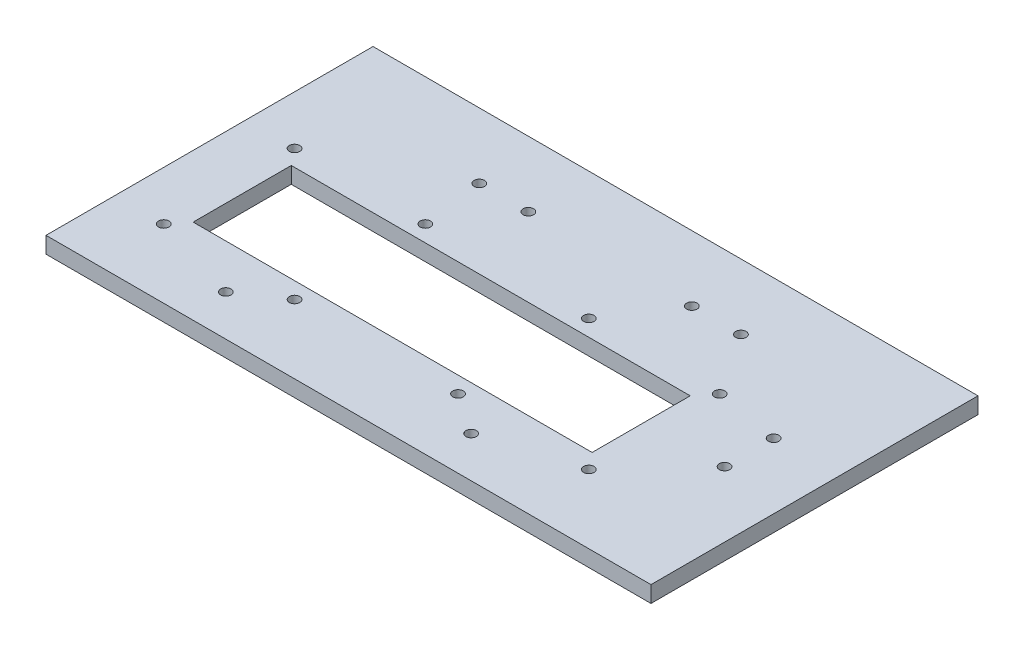
from build123d import *

# Parameters (mm, degrees)
SKETCH1_W           = 185
SKETCH1_H           = 100
SKETCH1_W_2         = 122
SKETCH1_H_2         = 30
BOSS_EXTRUDE1_DEPTH = 5
CUT_EXTRUDE2_REACH  = 7
SKETCH2_R           = 1.6
CUT_EXTRUDE3_REACH  = 7
SKETCH3_R           = 1.6
CUT_EXTRUDE4_REACH  = 7
SKETCH4_R           = 1.6
CUT_EXTRUDE5_REACH  = 7
SKETCH5_R           = 1.6


with BuildPart() as part:
    # Sketch1 → Boss-Extrude1 (new body)
    with BuildSketch(Plane(origin=(0, 0, 0), x_dir=(1, 0, 0), z_dir=(0, 1, 0))):
        with Locations((12.5, 9)):
            Rectangle(SKETCH1_W, SKETCH1_H)
        Rectangle(SKETCH1_W_2, SKETCH1_H_2, mode=Mode.SUBTRACT)
    extrude(amount=BOSS_EXTRUDE1_DEPTH)

    # Sketch2 → Cut-Extrude2 (cut, up to next)
    with BuildSketch(Plane(origin=(0, 0, 0), x_dir=(1, 0, 0), z_dir=(0, 1, 0)), mode=Mode.PRIVATE) as cut_extrude2_sk1:
        with Locations((-25, 20)):
            Circle(SKETCH2_R)
    cut_extrude2_tool1 = extrude(cut_extrude2_sk1.sketch, amount=CUT_EXTRUDE2_REACH, mode=Mode.PRIVATE) & part.part
    add(cut_extrude2_tool1.solids().sort_by_distance((-25, 0, -20))[0], mode=Mode.SUBTRACT)
    # Sketch2 → Cut-Extrude2 (cut, up to next)
    with BuildSketch(Plane(origin=(0, 0, 0), x_dir=(1, 0, 0), z_dir=(0, 1, 0)), mode=Mode.PRIVATE) as cut_extrude2_sk2:
        with Locations((25, 20)):
            Circle(SKETCH2_R)
    cut_extrude2_tool2 = extrude(cut_extrude2_sk2.sketch, amount=CUT_EXTRUDE2_REACH, mode=Mode.PRIVATE) & part.part
    add(cut_extrude2_tool2.solids().sort_by_distance((25, 0, -20))[0], mode=Mode.SUBTRACT)
    # Sketch2 → Cut-Extrude2 (cut, up to next)
    with BuildSketch(Plane(origin=(0, 0, 0), x_dir=(1, 0, 0), z_dir=(0, 1, 0)), mode=Mode.PRIVATE) as cut_extrude2_sk3:
        with Locations((25, -20)):
            Circle(SKETCH2_R)
    cut_extrude2_tool3 = extrude(cut_extrude2_sk3.sketch, amount=CUT_EXTRUDE2_REACH, mode=Mode.PRIVATE) & part.part
    add(cut_extrude2_tool3.solids().sort_by_distance((25, 0, 20))[0], mode=Mode.SUBTRACT)
    # Sketch2 → Cut-Extrude2 (cut, up to next)
    with BuildSketch(Plane(origin=(0, 0, 0), x_dir=(1, 0, 0), z_dir=(0, 1, 0)), mode=Mode.PRIVATE) as cut_extrude2_sk4:
        with Locations((-25, -20)):
            Circle(SKETCH2_R)
    cut_extrude2_tool4 = extrude(cut_extrude2_sk4.sketch, amount=CUT_EXTRUDE2_REACH, mode=Mode.PRIVATE) & part.part
    add(cut_extrude2_tool4.solids().sort_by_distance((-25, 0, 20))[0], mode=Mode.SUBTRACT)
    # Sketch2 → Cut-Extrude2 (cut, up to next)
    with BuildSketch(Plane(origin=(0, 0, 0), x_dir=(1, 0, 0), z_dir=(0, 1, 0)), mode=Mode.PRIVATE) as cut_extrude2_sk5:
        with Locations((-65, 20)):
            Circle(SKETCH2_R)
    cut_extrude2_tool5 = extrude(cut_extrude2_sk5.sketch, amount=CUT_EXTRUDE2_REACH, mode=Mode.PRIVATE) & part.part
    add(cut_extrude2_tool5.solids().sort_by_distance((-65, 0, -20))[0], mode=Mode.SUBTRACT)
    # Sketch2 → Cut-Extrude2 (cut, up to next)
    with BuildSketch(Plane(origin=(0, 0, 0), x_dir=(1, 0, 0), z_dir=(0, 1, 0)), mode=Mode.PRIVATE) as cut_extrude2_sk6:
        with Locations((65, 20)):
            Circle(SKETCH2_R)
    cut_extrude2_tool6 = extrude(cut_extrude2_sk6.sketch, amount=CUT_EXTRUDE2_REACH, mode=Mode.PRIVATE) & part.part
    add(cut_extrude2_tool6.solids().sort_by_distance((65, 0, -20))[0], mode=Mode.SUBTRACT)
    # Sketch2 → Cut-Extrude2 (cut, up to next)
    with BuildSketch(Plane(origin=(0, 0, 0), x_dir=(1, 0, 0), z_dir=(0, 1, 0)), mode=Mode.PRIVATE) as cut_extrude2_sk7:
        with Locations((65, -20)):
            Circle(SKETCH2_R)
    cut_extrude2_tool7 = extrude(cut_extrude2_sk7.sketch, amount=CUT_EXTRUDE2_REACH, mode=Mode.PRIVATE) & part.part
    add(cut_extrude2_tool7.solids().sort_by_distance((65, 0, 20))[0], mode=Mode.SUBTRACT)
    # Sketch2 → Cut-Extrude2 (cut, up to next)
    with BuildSketch(Plane(origin=(0, 0, 0), x_dir=(1, 0, 0), z_dir=(0, 1, 0)), mode=Mode.PRIVATE) as cut_extrude2_sk8:
        with Locations((-65, -20)):
            Circle(SKETCH2_R)
    cut_extrude2_tool8 = extrude(cut_extrude2_sk8.sketch, amount=CUT_EXTRUDE2_REACH, mode=Mode.PRIVATE) & part.part
    add(cut_extrude2_tool8.solids().sort_by_distance((-65, 0, 20))[0], mode=Mode.SUBTRACT)

    # Sketch3 → Cut-Extrude3 (cut, up to next)
    with BuildSketch(Plane(origin=(0, 5, 0), x_dir=(1, 0, 0), z_dir=(0, 1, 0)), mode=Mode.PRIVATE) as cut_extrude3_sk1:
        with Locations((-27.5, 39)):
            Circle(SKETCH3_R)
    cut_extrude3_tool1 = extrude(cut_extrude3_sk1.sketch, amount=-CUT_EXTRUDE3_REACH, mode=Mode.PRIVATE) & part.part
    add(cut_extrude3_tool1.solids().sort_by_distance((-27.5, 5, -39))[0], mode=Mode.SUBTRACT)
    # Sketch3 → Cut-Extrude3 (cut, up to next)
    with BuildSketch(Plane(origin=(0, 5, 0), x_dir=(1, 0, 0), z_dir=(0, 1, 0)), mode=Mode.PRIVATE) as cut_extrude3_sk2:
        with Locations((-12.5, 39)):
            Circle(SKETCH3_R)
    cut_extrude3_tool2 = extrude(cut_extrude3_sk2.sketch, amount=-CUT_EXTRUDE3_REACH, mode=Mode.PRIVATE) & part.part
    add(cut_extrude3_tool2.solids().sort_by_distance((-12.5, 5, -39))[0], mode=Mode.SUBTRACT)
    # Sketch3 → Cut-Extrude3 (cut, up to next)
    with BuildSketch(Plane(origin=(0, 5, 0), x_dir=(1, 0, 0), z_dir=(0, 1, 0)), mode=Mode.PRIVATE) as cut_extrude3_sk3:
        with Locations((37.5, 39)):
            Circle(SKETCH3_R)
    cut_extrude3_tool3 = extrude(cut_extrude3_sk3.sketch, amount=-CUT_EXTRUDE3_REACH, mode=Mode.PRIVATE) & part.part
    add(cut_extrude3_tool3.solids().sort_by_distance((37.5, 5, -39))[0], mode=Mode.SUBTRACT)
    # Sketch3 → Cut-Extrude3 (cut, up to next)
    with BuildSketch(Plane(origin=(0, 5, 0), x_dir=(1, 0, 0), z_dir=(0, 1, 0)), mode=Mode.PRIVATE) as cut_extrude3_sk4:
        with Locations((52.5, 39)):
            Circle(SKETCH3_R)
    cut_extrude3_tool4 = extrude(cut_extrude3_sk4.sketch, amount=-CUT_EXTRUDE3_REACH, mode=Mode.PRIVATE) & part.part
    add(cut_extrude3_tool4.solids().sort_by_distance((52.5, 5, -39))[0], mode=Mode.SUBTRACT)

    # Sketch4 → Cut-Extrude4 (cut, up to next)
    with BuildSketch(Plane(origin=(0, 5, 0), x_dir=(1, 0, 0), z_dir=(0, 1, 0)), mode=Mode.PRIVATE) as cut_extrude4_sk1:
        with Locations((-37.5, -28.5)):
            Circle(SKETCH4_R)
    cut_extrude4_tool1 = extrude(cut_extrude4_sk1.sketch, amount=-CUT_EXTRUDE4_REACH, mode=Mode.PRIVATE) & part.part
    add(cut_extrude4_tool1.solids().sort_by_distance((-37.5, 5, 28.5))[0], mode=Mode.SUBTRACT)
    # Sketch4 → Cut-Extrude4 (cut, up to next)
    with BuildSketch(Plane(origin=(0, 5, 0), x_dir=(1, 0, 0), z_dir=(0, 1, 0)), mode=Mode.PRIVATE) as cut_extrude4_sk2:
        with Locations((37.5, -28.5)):
            Circle(SKETCH4_R)
    cut_extrude4_tool2 = extrude(cut_extrude4_sk2.sketch, amount=-CUT_EXTRUDE4_REACH, mode=Mode.PRIVATE) & part.part
    add(cut_extrude4_tool2.solids().sort_by_distance((37.5, 5, 28.5))[0], mode=Mode.SUBTRACT)

    # Sketch5 → Cut-Extrude5 (cut, up to next)
    with BuildSketch(Plane.XZ, mode=Mode.PRIVATE) as cut_extrude5_sk1:
        with Locations((85, -1.5)):
            Circle(SKETCH5_R)
    cut_extrude5_tool1 = extrude(cut_extrude5_sk1.sketch, amount=-CUT_EXTRUDE5_REACH, mode=Mode.PRIVATE) & part.part
    add(cut_extrude5_tool1.solids().sort_by_distance((85, 0, -1.5))[0], mode=Mode.SUBTRACT)
    # Sketch5 → Cut-Extrude5 (cut, up to next)
    with BuildSketch(Plane.XZ, mode=Mode.PRIVATE) as cut_extrude5_sk2:
        with Locations((85, -16.5)):
            Circle(SKETCH5_R)
    cut_extrude5_tool2 = extrude(cut_extrude5_sk2.sketch, amount=-CUT_EXTRUDE5_REACH, mode=Mode.PRIVATE) & part.part
    add(cut_extrude5_tool2.solids().sort_by_distance((85, 0, -16.5))[0], mode=Mode.SUBTRACT)


solid = part.part
